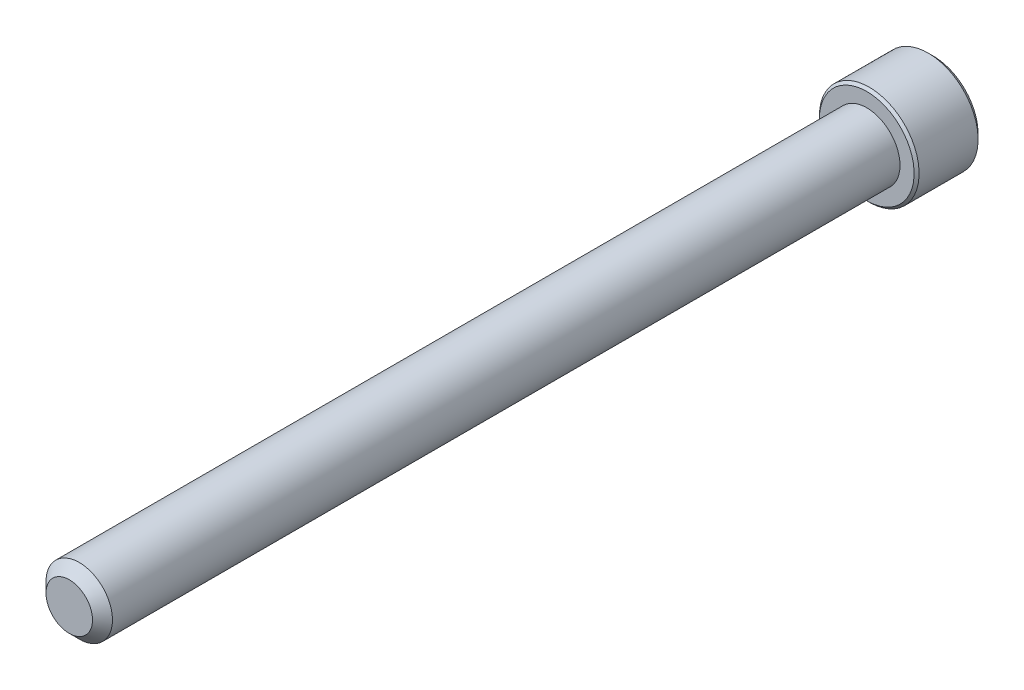
from build123d import *

# Parameters (mm, degrees)
SKETCH1_R          = 3.175
EXTRUDE1_DEPTH     = 76.2
CHAMFER3_SIZE      = 0.9525
SKETCH6_R          = 4.7625
EXTRUDE2_DEPTH     = 6.35
CUT_EXTRUDE1_DEPTH = 3.571875
CHAMFER1_SIZE      = 0.47625
CHAMFER2_SIZE      = 0.238125


with BuildPart() as part:
    # Sketch1 → Extrude1 (new body)
    with BuildSketch(Plane.XY):
        Circle(SKETCH1_R)
    extrude(amount=-EXTRUDE1_DEPTH)

    # Chamfer3
    chamfer3_edges = [part.edges().sort_by_distance(p)[0] for p in [
        (-3.175, 0, 0),
    ]]
    chamfer(chamfer3_edges, length=CHAMFER3_SIZE)

    # Sketch6 → Extrude2 (add)
    with BuildSketch(Plane(origin=(0, 0, -76.2), x_dir=(-1, 0, 0), z_dir=(0, 0, -1))):
        Circle(SKETCH6_R)
    extrude(amount=EXTRUDE2_DEPTH)

    # Sketch7 → Cut-Extrude1 (cut)
    with BuildSketch(Plane(origin=(0, 0, -82.55), x_dir=(-1, 0, 0), z_dir=(0, 0, -1))):
        Polygon((0, 2.749630657), (-2.38125, 1.374815329), (-2.38125, -1.374815329), (0, -2.749630657), (2.38125, -1.374815329), (2.38125, 1.374815329), align=None)
    extrude(amount=-CUT_EXTRUDE1_DEPTH, mode=Mode.SUBTRACT)

    # Cut-Extrude2 cone 1 section (through the dimple's axis) → Cut-Extrude2 (revolve, cut)
    with BuildSketch(Plane(origin=(0, 0, -82.55), x_dir=(0, 1, 0), z_dir=(1, 0, 0))):
        Polygon((0, 0), (2.749630657, 0), (0, 2.749630657), align=None)
    revolve(axis=Axis((0, 0, -82.55), (0, 0, 1)), mode=Mode.SUBTRACT)

    # Chamfer1
    chamfer1_edges = [part.edges().sort_by_distance(p)[0] for p in [
        (4.7625, 0, -82.55),
    ]]
    chamfer(chamfer1_edges, length=CHAMFER1_SIZE)

    # Chamfer2
    chamfer2_edges = [part.edges().sort_by_distance(p)[0] for p in [
        (4.7625, 0, -76.2),
    ]]
    chamfer(chamfer2_edges, length=CHAMFER2_SIZE)


solid = part.part
